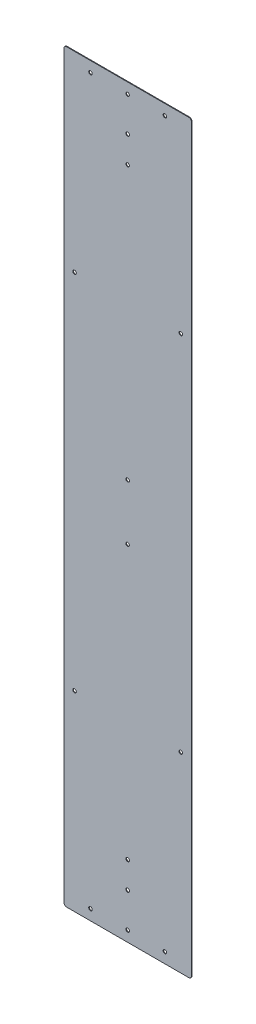
from build123d import *

# Parameters (mm, degrees)
SKETCH1_W                    = 304.8
SKETCH1_H                    = 1781.175
BOSS_EXTRUDE1_DEPTH          = 1.5875
F_5_16_CLEARANCE_HOLE1_D     = 8.4328
F_5_16_CLEARANCE_HOLE1_DEPTH = 1.5875
FILLET4_R                    = 6.35


with BuildPart() as part:
    # Sketch1 → Boss-Extrude1 (new body)
    with BuildSketch(Plane.XY):
        Rectangle(SKETCH1_W, SKETCH1_H)
    extrude(amount=BOSS_EXTRUDE1_DEPTH)

    # 5/16 Clearance Hole1
    with Locations(Plane.XY.offset(1.5875)):
        with Locations((0, 865.1875), (-127, 433.3875), (127, 433.3875), (0, 66.675), (0, -66.675), (-127, -433.3875), (127, -433.3875), (0, -865.1875), (0, 782.6375), (0, 719.1375), (0, -782.6375), (0, -719.1375), (-88.9, 865.1875), (88.9, 865.1875), (-88.9, -865.1875), (88.9, -865.1875)):
            Hole(F_5_16_CLEARANCE_HOLE1_D / 2, depth=F_5_16_CLEARANCE_HOLE1_DEPTH)

    # Fillet4
    fillet4_edges = [part.edges().sort_by_distance(p)[0] for p in [
        (152.4, -890.5875, 0.79375),
        (-152.4, -890.5875, 0.79375),
        (-152.4, 890.5875, 0.79375),
        (152.4, 890.5875, 0.79375),
    ]]
    fillet(fillet4_edges, radius=FILLET4_R)


solid = part.part
